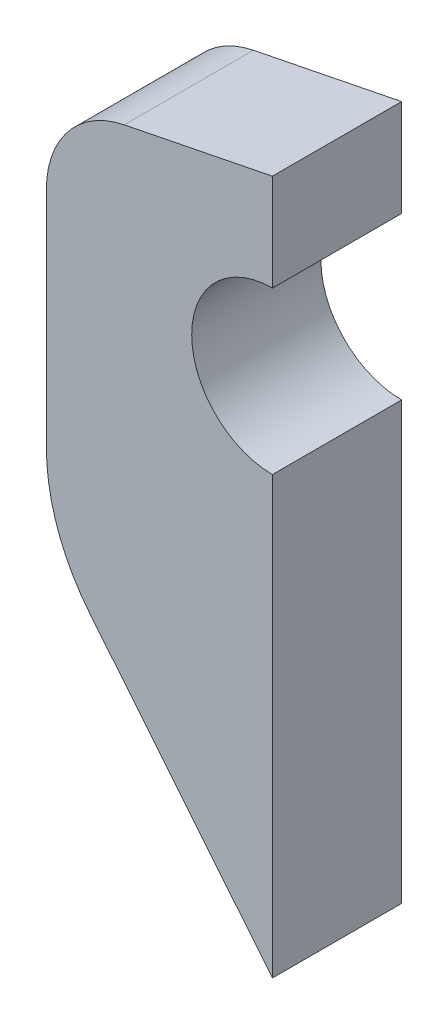
from build123d import *

# Parameters (mm, degrees)
EXTRUDE_1_DEPTH = 4
FILLET_1_R      = 3
FILLET_2_R      = 6


with BuildPart() as part:
    # ｽｹｯﾁ1 → ﾎﾞｽ - 押し出し1 (new body)
    with BuildSketch(Plane.XY):
        with BuildLine():
            Line((0, 2.5), (0, 5.5))
            Line((0, 5.5), (-7, 4.1))
            Line((-7, 4.1), (-7, -7.4))
            Line((-7, -7.4), (0, -16))
            Line((0, -16), (0, -2.5))
            ThreePointArc((0, -2.5), (-2.5, 0), (0, 2.5))
        make_face()
    extrude(amount=EXTRUDE_1_DEPTH)

    # ﾌｨﾚｯﾄ1
    fillet_1_edges = [part.edges().sort_by_distance(p)[0] for p in [
        (-7, 4.1, 2),
    ]]
    fillet(fillet_1_edges, radius=FILLET_1_R)

    # ﾌｨﾚｯﾄ2
    fillet_2_edges = [part.edges().sort_by_distance(p)[0] for p in [
        (-7, -7.4, 2),
    ]]
    fillet(fillet_2_edges, radius=FILLET_2_R)


solid = part.part
